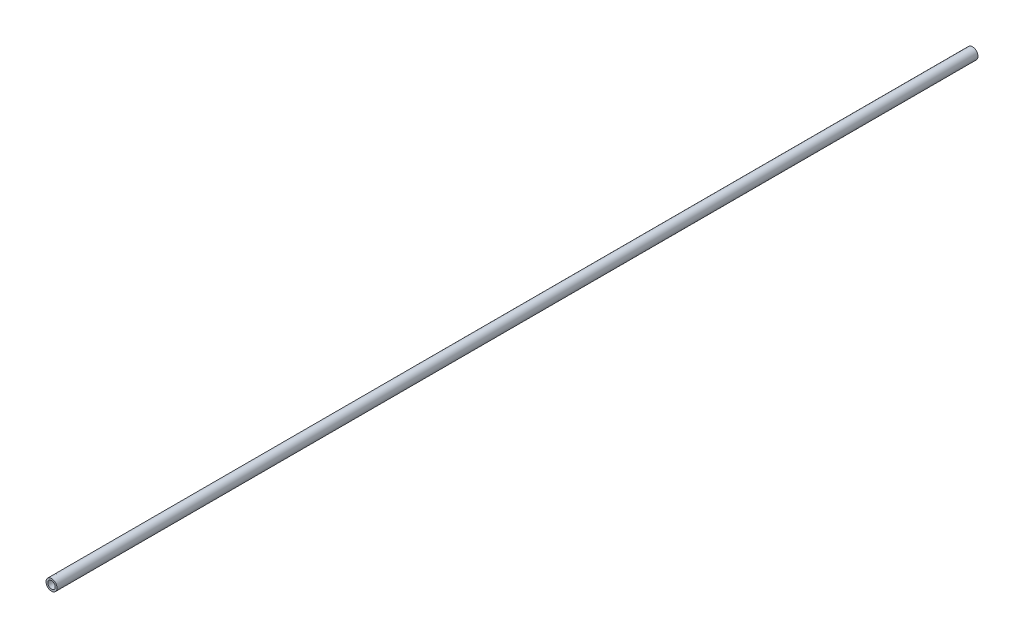
from build123d import *

# Parameters (mm, degrees)
SKETCH_1_R      = 3
SKETCH_1_R_2    = 2
EXTRUDE_1_DEPTH = 250


with BuildPart() as part:
    # Эскиз1 → Бобышка-Вытянуть1 (new body, symmetric)
    with BuildSketch(Plane.XY):
        Circle(SKETCH_1_R)
        Circle(SKETCH_1_R_2, mode=Mode.SUBTRACT)
    extrude(amount=EXTRUDE_1_DEPTH, both=True)


solid = part.part
